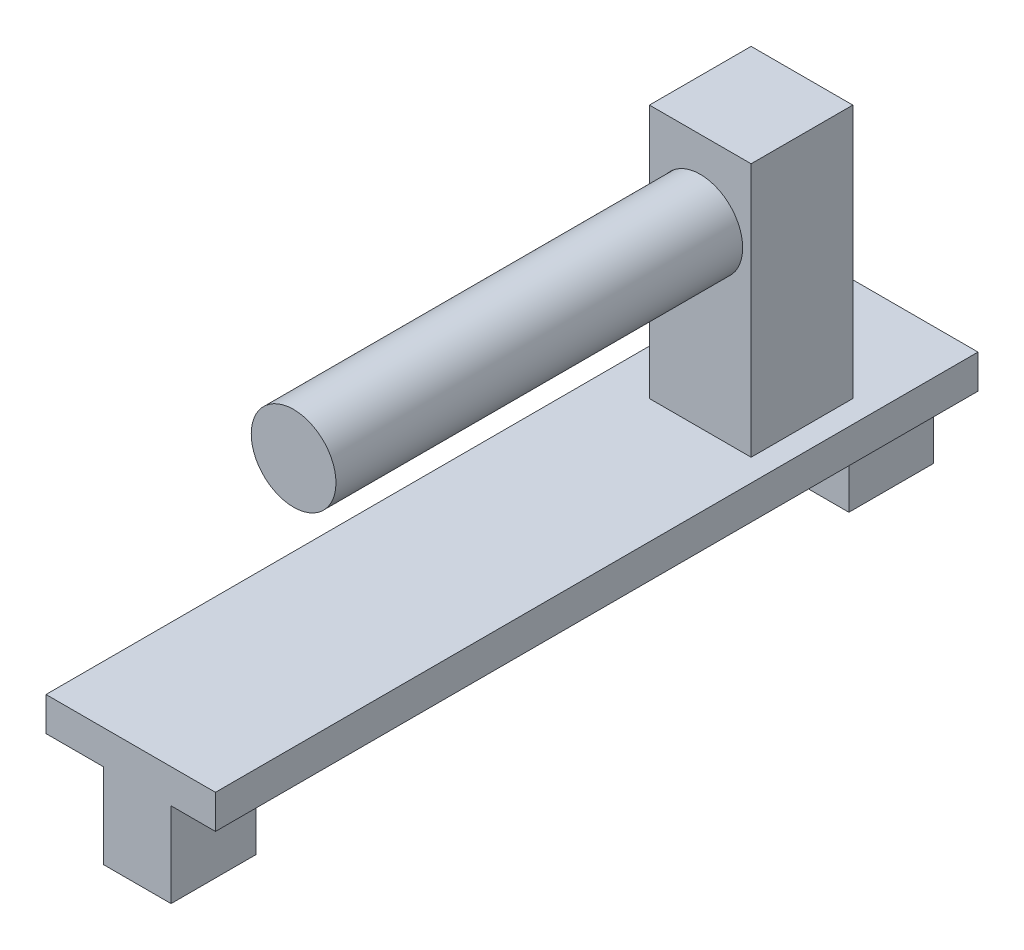
from build123d import *

# Parameters (mm, degrees)
SKETCH1_W           = 6
SKETCH1_H           = 6
BOSS_EXTRUDE1_DEPTH = 15
SKETCH3_W           = 10
SKETCH3_H           = 45
BOSS_EXTRUDE2_DEPTH = 2
SKETCH4_W           = 4
SKETCH4_H           = 5
BOSS_EXTRUDE3_DEPTH = 2
SKETCH5_W           = 4
SKETCH5_H           = 5
BOSS_EXTRUDE4_DEPTH = 2
SKETCH6_W           = 4
SKETCH6_H           = 3
BOSS_EXTRUDE5_DEPTH = 3
SKETCH7_W           = 4
SKETCH7_H           = 3
BOSS_EXTRUDE6_DEPTH = 3
SKETCH8_R           = 2.5
CUT_EXTRUDE1_DEPTH  = 1
SKETCH9_R           = 2.5
BOSS_EXTRUDE7_DEPTH = 25


with BuildPart() as part:
    # Sketch1 → Boss-Extrude1 (new body)
    with BuildSketch(Plane(origin=(0, 0, 0), x_dir=(1, 0, 0), z_dir=(0, 1, 0))):
        Rectangle(SKETCH1_W, SKETCH1_H)
    extrude(amount=BOSS_EXTRUDE1_DEPTH)

    # Sketch3 → Boss-Extrude2 (add)
    with BuildSketch(Plane(origin=(0, 0, 0), x_dir=(1, 0, 0), z_dir=(0, 1, 0))):
        with Locations((-0.682406889, -13.428719973)):
            Rectangle(SKETCH3_W, SKETCH3_H)
    extrude(amount=-BOSS_EXTRUDE2_DEPTH)

    # Sketch4 → Boss-Extrude3 (add)
    with BuildSketch(Plane.XY.offset(35.928719973)):
        with Locations((-0.302179452, -4.5)):
            Rectangle(SKETCH4_W, SKETCH4_H)
    extrude(amount=-BOSS_EXTRUDE3_DEPTH)

    # Sketch5 → Boss-Extrude4 (add)
    with BuildSketch(Plane(origin=(0, 0, -9.071280027), x_dir=(-1, 0, 0), z_dir=(0, 0, -1))):
        with Locations((0.302179452, -4.5)):
            Rectangle(SKETCH5_W, SKETCH5_H)
    extrude(amount=-BOSS_EXTRUDE4_DEPTH)

    # Sketch6 → Boss-Extrude5 (add)
    with BuildSketch(Plane(origin=(0, 0, 33.928719973), x_dir=(-1, 0, 0), z_dir=(0, 0, -1))):
        with Locations((0.302179452, -5.5)):
            Rectangle(SKETCH6_W, SKETCH6_H)
    extrude(amount=BOSS_EXTRUDE5_DEPTH)

    # Sketch7 → Boss-Extrude6 (add)
    with BuildSketch(Plane.XY.offset(-7.071280027)):
        with Locations((-0.302179452, -5.5)):
            Rectangle(SKETCH7_W, SKETCH7_H)
    extrude(amount=BOSS_EXTRUDE6_DEPTH)

    # Sketch8 → Cut-Extrude1 (cut)
    with BuildSketch(Plane.XY.offset(3)):
        with Locations((0, 10.46201193)):
            Circle(SKETCH8_R)
    extrude(amount=-CUT_EXTRUDE1_DEPTH, mode=Mode.SUBTRACT)

    # Sketch9 → Boss-Extrude7 (add)
    with BuildSketch(Plane.XY.offset(2)):
        with Locations((0, 10.44523286)):
            Circle(SKETCH9_R)
    extrude(amount=BOSS_EXTRUDE7_DEPTH)


solid = part.part
